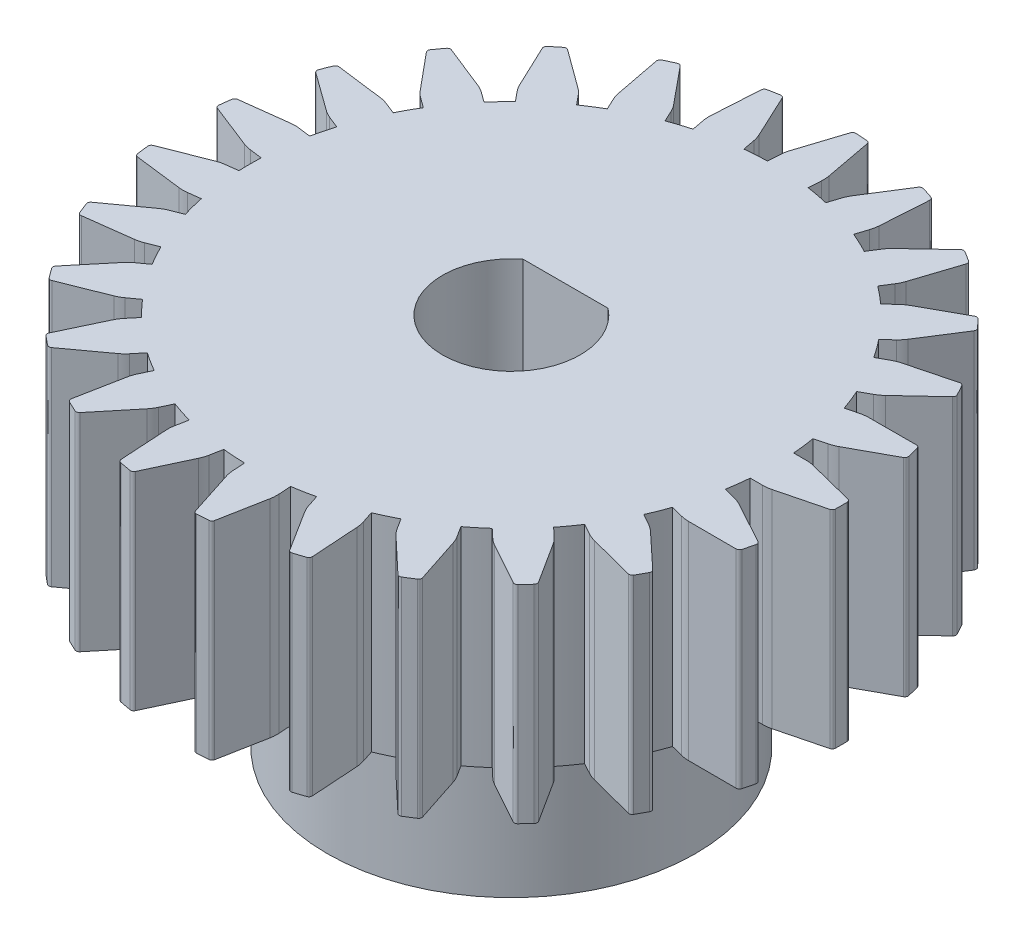
from build123d import *

# Parameters (mm, degrees)
BOSS_EXTRUDE1_DEPTH = 12.4
BOSS_EXTRUDE2_DEPTH = 10
SKETCH3_R           = 1
CUT_EXTRUDE1_DEPTH  = 10
CUT_EXTRUDE2_DEPTH  = 10


with BuildPart() as part:
    # Sketch1 → Boss-Extrude1 (new body)
    with BuildSketch(Plane(origin=(0, 0, 0), x_dir=(1, 0, 0), z_dir=(0, 1, 0))):
        with BuildLine():
            Line((-19.960600311, 2.711777504), (-17.312328167, 1.670742606))
            ThreePointArc((-17.312328167, 1.670742606), (-17.075641243, 1.594318398), (-16.831298839, 1.547862515))
            Line((-16.831298839, 1.547862515), (-16.087384111, 1.45388423))
            ThreePointArc((-16.087384111, 1.45388423), (-16.101516413, 0.788947145), (-16.087384111, 0.124010059))
            Line((-16.087384111, 0.124010059), (-16.831298839, 0.030031774))
            ThreePointArc((-16.831298839, 0.030031774), (-17.075641243, -0.016424108), (-17.312328167, -0.092848316))
            Line((-17.312328167, -0.092848316), (-19.960600311, -1.133883215))
            ThreePointArc((-19.960600311, -1.133883215), (-20.058551152, -1.21649133), (-20.086263615, -1.341593239))
            ThreePointArc((-20.086263615, -1.341593239), (-20.045781764, -1.686384218), (-19.999245773, -2.030410382))
            ThreePointArc((-19.999245773, -2.030410382), (-19.941292369, -2.144690175), (-19.825875031, -2.200343621))
            Line((-19.825875031, -2.200343621), (-17.001908374, -2.550073993))
            ThreePointArc((-17.001908374, -2.550073993), (-16.753651478, -2.56523555), (-16.505432431, -2.54946645))
            Line((-16.505432431, -2.54946645), (-15.761517704, -2.455488164))
            ThreePointArc((-15.761517704, -2.455488164), (-15.609842885, -3.103049589), (-15.430791446, -3.743581893))
            Line((-15.430791446, -3.743581893), (-16.127963275, -4.019611747))
            ThreePointArc((-16.127963275, -4.019611747), (-16.353076106, -4.125373617), (-16.563321147, -4.258258463))
            Line((-16.563321147, -4.258258463), (-18.869498101, -5.925185837))
            ThreePointArc((-18.869498101, -5.925185837), (-18.943827833, -6.02955805), (-18.939558078, -6.157621461))
            ThreePointArc((-18.939558078, -6.157621461), (-18.814602009, -6.481512771), (-18.683972204, -6.80315769))
            ThreePointArc((-18.683972204, -6.80315769), (-18.599419285, -6.899434747), (-18.473787545, -6.924636613))
            Line((-18.473787545, -6.924636613), (-15.651566587, -6.561087613))
            ThreePointArc((-15.651566587, -6.561087613), (-15.407338611, -6.514033862), (-15.170839438, -6.437030611))
            Line((-15.170839438, -6.437030611), (-14.473667609, -6.161000757))
            ThreePointArc((-14.473667609, -6.161000757), (-14.165715956, -6.750497855), (-13.832995841, -7.326378377))
            Line((-13.832995841, -7.326378377), (-14.439618902, -7.767115829))
            ThreePointArc((-14.439618902, -7.767115829), (-14.631357491, -7.92553828), (-14.801950181, -8.106534119))
            Line((-14.801950181, -8.106534119), (-16.621126364, -10.29461479))
            ThreePointArc((-16.621126364, -10.29461479), (-16.667164578, -10.414193011), (-16.631180889, -10.53717123))
            ThreePointArc((-16.631180889, -10.53717123), (-16.429602052, -10.819811588), (-16.223086384, -11.098865129))
            ThreePointArc((-16.223086384, -11.098865129), (-16.117246719, -11.171090009), (-15.989294482, -11.164256769))
            Line((-15.989294482, -11.164256769), (-13.346149745, -10.110271518))
            ThreePointArc((-13.346149745, -10.110271518), (-13.121296433, -10.003959019), (-12.911377246, -9.870560014))
            Line((-12.911377246, -9.870560014), (-12.304754185, -9.429822562))
            ThreePointArc((-12.304754185, -9.429822562), (-11.859875432, -9.924215063), (-11.39439267, -10.399259111))
            Line((-11.39439267, -10.399259111), (-11.872350605, -10.977011007))
            ThreePointArc((-11.872350605, -10.977011007), (-12.018667312, -11.178139773), (-12.138888684, -11.395873972))
            Line((-12.138888684, -11.395873972), (-13.356758567, -13.967622785))
            ThreePointArc((-13.356758567, -13.967622785), (-13.371612511, -14.094893475), (-13.306175877, -14.205059327))
            ThreePointArc((-13.306175877, -14.205059327), (-13.040640211, -14.4286894), (-12.771214818, -14.647617603))
            ThreePointArc((-12.771214818, -14.647617603), (-12.650738704, -14.691252152), (-12.52850568, -14.652813163))
            Line((-12.52850568, -14.652813163), (-10.230515668, -12.97461743))
            ThreePointArc((-10.230515668, -12.97461743), (-10.039165379, -12.815726189), (-9.869016173, -12.63431338))
            Line((-9.869016173, -12.63431338), (-9.391058239, -12.056561485))
            ThreePointArc((-9.391058239, -12.056561485), (-8.837205754, -12.424784889), (-8.268208338, -12.7691437))
            Line((-8.268208338, -12.7691437), (-8.587469292, -13.447607762))
            ThreePointArc((-8.587469292, -13.447607762), (-8.679170501, -13.678805183), (-8.741466603, -13.919596701))
            Line((-8.741466603, -13.919596701), (-9.281506943, -16.71342122))
            ThreePointArc((-9.281506943, -16.71342122), (-9.264243289, -16.840387493), (-9.173465334, -16.930818853))
            ThreePointArc((-9.173465334, -16.930818853), (-8.860657421, -17.081387142), (-8.545251293, -17.226433942))
            ThreePointArc((-8.545251293, -17.226433942), (-8.417708687, -17.23873644), (-8.308875225, -17.171106965))
            Line((-8.308875225, -17.171106965), (-6.500431103, -14.974147961))
            ThreePointArc((-6.500431103, -14.974147961), (-6.35460708, -14.772661699), (-6.234918955, -14.55463392))
            Line((-6.234918955, -14.55463392), (-5.915658002, -13.876169858))
            ThreePointArc((-5.915658002, -13.876169858), (-5.287632375, -14.095087335), (-4.650872505, -14.287123577))
            Line((-4.650872505, -14.287123577), (-4.791376138, -15.023669413))
            ThreePointArc((-4.791376138, -15.023669413), (-4.822699924, -15.270408506), (-4.823156465, -15.519127527))
            Line((-4.823156465, -15.519127527), (-4.651434539, -18.359481482))
            ThreePointArc((-4.651434539, -18.359481482), (-4.603138027, -18.478165579), (-4.492722664, -18.543180313))
            ThreePointArc((-4.492722664, -18.543180313), (-4.152297376, -18.611226057), (-3.810728639, -18.673277631))
            ThreePointArc((-3.810728639, -18.673277631), (-3.684133511, -18.653475067), (-3.59553802, -18.560904516))
            Line((-3.59553802, -18.560904516), (-2.390270982, -15.983225253))
            ThreePointArc((-2.390270982, -15.983225253), (-2.299135884, -15.751804093), (-2.237429286, -15.510860831))
            Line((-2.237429286, -15.510860831), (-2.096925653, -14.774314995))
            ThreePointArc((-2.096925653, -14.774314995), (-1.434188044, -14.830171155), (-0.769675685, -14.857818485))
            Line((-0.769675685, -14.857818485), (-0.722593637, -15.606166212))
            ThreePointArc((-0.722593637, -15.606166212), (-0.691571811, -15.852943452), (-0.630160104, -16.093962044))
            Line((-0.630160104, -16.093962044), (0.242534167, -18.80237555))
            ThreePointArc((0.242534167, -18.80237555), (0.31882889, -18.905320114), (0.441943858, -18.940833106))
            ThreePointArc((0.441943858, -18.940833106), (0.788596348, -18.922080742), (1.134865674, -18.897238161))
            ThreePointArc((1.134865674, -18.897238161), (1.252558885, -18.846574802), (1.315349627, -18.734879722))
            Line((1.315349627, -18.734879722), (1.841708219, -15.938445271))
            ThreePointArc((1.841708219, -15.938445271), (1.872428038, -15.691630254), (1.872275857, -15.442910861))
            Line((1.872275857, -15.442910861), (1.825193809, -14.694563134))
            ThreePointArc((1.825193809, -14.694563134), (2.48100116, -14.583848329), (3.131512253, -14.445369564))
            Line((3.131512253, -14.445369564), (3.363221644, -15.158497742))
            ThreePointArc((3.363221644, -15.158497742), (3.454639865, -15.389807206), (3.574061098, -15.607981285))
            Line((3.574061098, -15.607981285), (5.092893122, -18.014274761))
            ThreePointArc((5.092893122, -18.014274761), (5.192392178, -18.095011407), (5.320470985, -18.098791245))
            ThreePointArc((5.320470985, -18.098791245), (5.651569226, -17.994419052), (5.980781765, -17.884243267))
            ThreePointArc((5.980781765, -17.884243267), (6.082177964, -17.805902479), (6.115218582, -17.682101083))
            Line((6.115218582, -17.682101083), (5.929595683, -14.842621703))
            ThreePointArc((5.929595683, -14.842621703), (5.897969983, -14.595921126), (5.835968586, -14.355053556))
            Line((5.835968586, -14.355053556), (5.604259195, -13.641925379))
            ThreePointArc((5.604259195, -13.641925379), (6.2119295, -13.371596226), (6.807565322, -13.075692496))
            Line((6.807565322, -13.075692496), (7.209342902, -13.708792658))
            ThreePointArc((7.209342902, -13.708792658), (7.355413377, -13.910100323), (7.525340459, -14.09172121))
            Line((7.525340459, -14.09172121), (9.594876435, -16.044698387))
            ThreePointArc((9.594876435, -16.044698387), (9.711327932, -16.098154133), (9.836322916, -16.069963317))
            ThreePointArc((9.836322916, -16.069963317), (10.131062788, -15.886529384), (10.422532906, -15.697943144))
            ThreePointArc((10.422532906, -15.697943144), (10.501260995, -15.596847367), (10.502475426, -15.468718553))
            Line((10.502475426, -15.468718553), (9.616534405, -12.764609176))
            ThreePointArc((9.616534405, -12.764609176), (9.524550347, -12.533524143), (9.404595509, -12.315642991))
            Line((9.404595509, -12.315642991), (9.002817928, -11.682542829))
            ThreePointArc((9.002817928, -11.682542829), (9.524169027, -11.269585105), (10.027503589, -10.834849129))
            Line((10.027503589, -10.834849129), (10.574104195, -11.348141264))
            ThreePointArc((10.574104195, -11.348141264), (10.765648778, -11.506798229), (10.975404566, -11.640454014))
            Line((10.975404566, -11.640454014), (13.465607937, -13.017402154))
            ThreePointArc((13.465607937, -13.017402154), (13.5916948, -13.040218179), (13.705752066, -12.981828041))
            ThreePointArc((13.705752066, -12.981828041), (13.945613979, -12.730858197), (14.181027537, -12.47571107))
            ThreePointArc((14.181027537, -12.47571107), (14.232140741, -12.358212524), (14.201452677, -12.233807094))
            Line((14.201452677, -12.233807094), (12.670860467, -9.834976859))
            ThreePointArc((12.670860467, -9.834976859), (12.524297746, -9.634027293), (12.353926671, -9.452822833))
            Line((12.353926671, -9.452822833), (11.807326064, -8.939530697))
            ThreePointArc((11.807326064, -8.939530697), (12.209599549, -8.409892054), (12.589006489, -7.863639892))
            Line((12.589006489, -7.863639892), (13.246085196, -8.224871968))
            ThreePointArc((13.246085196, -8.224871968), (13.471068436, -8.330909232), (13.707473202, -8.408201832))
            Line((13.707473202, -8.408201832), (16.461875333, -9.122602218))
            ThreePointArc((16.461875333, -9.122602218), (16.589675061, -9.113344909), (16.68562797, -9.028424315))
            ThreePointArc((16.68562797, -9.028424315), (16.855540518, -8.725687919), (17.020105616, -8.420011737))
            ThreePointArc((17.020105616, -8.420011737), (17.040392304, -8.293493286), (16.979729991, -8.180628093))
            Line((16.979729991, -8.180628093), (14.900659329, -6.237804325))
            ThreePointArc((14.900659329, -6.237804325), (14.70872702, -6.079616625), (14.498644749, -5.9464746))
            Line((14.498644749, -5.9464746), (13.841566042, -5.585242524))
            ThreePointArc((13.841566042, -5.585242524), (14.099485591, -4.972202105), (14.331125376, -4.34875679))
            Line((14.331125376, -4.34875679), (15.057395512, -4.535231267))
            ThreePointArc((15.057395512, -4.535231267), (15.301680885, -4.581986119), (15.549880448, -4.598058955))
            Line((15.549880448, -4.598058955), (18.395412123, -4.605023184))
            ThreePointArc((18.395412123, -4.605023184), (18.516894587, -4.56427421), (18.588714067, -4.458159035))
            ThreePointArc((18.588714067, -4.458159035), (18.678001019, -4.122678127), (18.761377427, -3.785679648))
            ThreePointArc((18.761377427, -3.785679648), (18.749562912, -3.658090913), (18.662737985, -3.563857692))
            Line((18.662737985, -3.563857692), (16.165824528, -2.199115153))
            ThreePointArc((16.165824528, -2.199115153), (15.940582444, -2.093628835), (15.703989218, -2.016915048))
            Line((15.703989218, -2.016915048), (14.977719083, -1.830440572))
            ThreePointArc((14.977719083, -1.830440572), (15.075078663, -1.17251796), (15.144396513, -0.511052855))
            Line((15.144396513, -0.511052855), (15.894223853, -0.511052855))
            ThreePointArc((15.894223853, -0.511052855), (16.142462011, -0.495587515), (16.386861081, -0.449430672))
            Line((16.386861081, -0.449430672), (19.144727078, 0.251478844))
            ThreePointArc((19.144727078, 0.251478844), (19.25225909, 0.321159074), (19.295432458, 0.441801224))
            ThreePointArc((19.295432458, 0.441801224), (19.298483587, 0.788947145), (19.295432458, 1.136093066))
            ThreePointArc((19.295432458, 1.136093066), (19.25225909, 1.256735215), (19.144727078, 1.326415445))
            Line((19.144727078, 1.326415445), (16.386861081, 2.027324962))
            ThreePointArc((16.386861081, 2.027324962), (16.142462011, 2.073481805), (15.894223853, 2.088947144))
            Line((15.894223853, 2.088947144), (15.144396513, 2.088947144))
            ThreePointArc((15.144396513, 2.088947144), (15.075078663, 2.75041225), (14.977719083, 3.408334861))
            Line((14.977719083, 3.408334861), (15.703989218, 3.594809337))
            ThreePointArc((15.703989218, 3.594809337), (15.940582444, 3.671523125), (16.165824528, 3.777009442))
            Line((16.165824528, 3.777009442), (18.662737985, 5.141751981))
            ThreePointArc((18.662737985, 5.141751981), (18.749562912, 5.235985203), (18.761377427, 5.363573938))
            ThreePointArc((18.761377427, 5.363573938), (18.678001019, 5.700572416), (18.588714067, 6.036053324))
            ThreePointArc((18.588714067, 6.036053324), (18.516894587, 6.142168499), (18.395412123, 6.182917473))
            Line((18.395412123, 6.182917473), (15.549880448, 6.175953244))
            ThreePointArc((15.549880448, 6.175953244), (15.301680885, 6.159880408), (15.057395512, 6.113125556))
            Line((15.057395512, 6.113125556), (14.331125376, 5.92665108))
            ThreePointArc((14.331125376, 5.92665108), (14.099485591, 6.550096394), (13.841566042, 7.163136814))
            Line((13.841566042, 7.163136814), (14.498644749, 7.52436889))
            ThreePointArc((14.498644749, 7.52436889), (14.70872702, 7.657510915), (14.900659329, 7.815698614))
            Line((14.900659329, 7.815698614), (16.979729991, 9.758522383))
            ThreePointArc((16.979729991, 9.758522383), (17.040392304, 9.871387575), (17.020105616, 9.997906026))
            ThreePointArc((17.020105616, 9.997906026), (16.855540518, 10.303582208), (16.68562797, 10.606318605))
            ThreePointArc((16.68562797, 10.606318605), (16.589675061, 10.691239198), (16.461875333, 10.700496507))
            Line((16.461875333, 10.700496507), (13.707473202, 9.986096121))
            ThreePointArc((13.707473202, 9.986096121), (13.471068436, 9.908803521), (13.246085196, 9.802766258))
            Line((13.246085196, 9.802766258), (12.589006489, 9.441534182))
            ThreePointArc((12.589006489, 9.441534182), (12.209599549, 9.987786343), (11.807326064, 10.517424987))
            Line((11.807326064, 10.517424987), (12.353926671, 11.030717122))
            ThreePointArc((12.353926671, 11.030717122), (12.524297746, 11.211921582), (12.670860467, 11.412871148))
            Line((12.670860467, 11.412871148), (14.201452677, 13.811701384))
            ThreePointArc((14.201452677, 13.811701384), (14.232140741, 13.936106813), (14.181027537, 14.053605359))
            ThreePointArc((14.181027537, 14.053605359), (13.945613979, 14.308752487), (13.705752066, 14.55972233))
            ThreePointArc((13.705752066, 14.55972233), (13.5916948, 14.618112469), (13.465607937, 14.595296443))
            Line((13.465607937, 14.595296443), (10.975404566, 13.218348304))
            ThreePointArc((10.975404566, 13.218348304), (10.765648778, 13.084692518), (10.574104195, 12.926035554))
            Line((10.574104195, 12.926035554), (10.027503589, 12.412743418))
            ThreePointArc((10.027503589, 12.412743418), (9.524169027, 12.847479394), (9.002817928, 13.260437118))
            Line((9.002817928, 13.260437118), (9.404595509, 13.893537281))
            ThreePointArc((9.404595509, 13.893537281), (9.524550347, 14.111418433), (9.616534405, 14.342503466))
            Line((9.616534405, 14.342503466), (10.502475426, 17.046612842))
            ThreePointArc((10.502475426, 17.046612842), (10.501260995, 17.174741657), (10.422532906, 17.275837433))
            ThreePointArc((10.422532906, 17.275837433), (10.131062788, 17.464423673), (9.836322916, 17.647857606))
            ThreePointArc((9.836322916, 17.647857606), (9.711327932, 17.676048422), (9.594876435, 17.622592676))
            Line((9.594876435, 17.622592676), (7.525340459, 15.669615499))
            ThreePointArc((7.525340459, 15.669615499), (7.355413377, 15.487994613), (7.209342902, 15.286686948))
            Line((7.209342902, 15.286686948), (6.807565322, 14.653586785))
            ThreePointArc((6.807565322, 14.653586785), (6.2119295, 14.949490516), (5.604259195, 15.219819668))
            Line((5.604259195, 15.219819668), (5.835968586, 15.932947846))
            ThreePointArc((5.835968586, 15.932947846), (5.897969983, 16.173815416), (5.929595683, 16.420515992))
            Line((5.929595683, 16.420515992), (6.115218582, 19.259995373))
            ThreePointArc((6.115218582, 19.259995373), (6.082177964, 19.383796769), (5.980781765, 19.462137556))
            ThreePointArc((5.980781765, 19.462137556), (5.651569226, 19.572313341), (5.320470985, 19.676685534))
            ThreePointArc((5.320470985, 19.676685534), (5.192392178, 19.672905696), (5.092893122, 19.592169051))
            Line((5.092893122, 19.592169051), (3.574061098, 17.185875574))
            ThreePointArc((3.574061098, 17.185875574), (3.454639865, 16.967701495), (3.363221644, 16.736392031))
            Line((3.363221644, 16.736392031), (3.131512253, 16.023263853))
            ThreePointArc((3.131512253, 16.023263853), (2.48100116, 16.161742618), (1.825193809, 16.272457424))
            Line((1.825193809, 16.272457424), (1.872275857, 17.020805151))
            ThreePointArc((1.872275857, 17.020805151), (1.872428038, 17.269524544), (1.841708219, 17.51633956))
            Line((1.841708219, 17.51633956), (1.315349627, 20.312774012))
            ThreePointArc((1.315349627, 20.312774012), (1.252558885, 20.424469091), (1.134865674, 20.47513245))
            ThreePointArc((1.134865674, 20.47513245), (0.788596348, 20.499975031), (0.441943858, 20.518727395))
            ThreePointArc((0.441943858, 20.518727395), (0.31882889, 20.483214403), (0.242534167, 20.380269839))
            Line((0.242534167, 20.380269839), (-0.630160104, 17.671856333))
            ThreePointArc((-0.630160104, 17.671856333), (-0.691571811, 17.430837741), (-0.722593637, 17.184060502))
            Line((-0.722593637, 17.184060502), (-0.769675685, 16.435712774))
            ThreePointArc((-0.769675685, 16.435712774), (-1.434188044, 16.408065444), (-2.096925653, 16.352209284))
            Line((-2.096925653, 16.352209284), (-2.237429286, 17.088755121))
            ThreePointArc((-2.237429286, 17.088755121), (-2.299135884, 17.329698382), (-2.390270982, 17.561119543))
            Line((-2.390270982, 17.561119543), (-3.59553802, 20.138798805))
            ThreePointArc((-3.59553802, 20.138798805), (-3.684133511, 20.231369356), (-3.810728639, 20.25117192))
            ThreePointArc((-3.810728639, 20.25117192), (-4.152297376, 20.189120346), (-4.492722664, 20.121074602))
            ThreePointArc((-4.492722664, 20.121074602), (-4.603138027, 20.056059869), (-4.651434539, 19.937375771))
            Line((-4.651434539, 19.937375771), (-4.823156465, 17.097021816))
            ThreePointArc((-4.823156465, 17.097021816), (-4.822699924, 16.848302796), (-4.791376138, 16.601563703))
            Line((-4.791376138, 16.601563703), (-4.650872505, 15.865017866))
            ThreePointArc((-4.650872505, 15.865017866), (-5.287632375, 15.672981625), (-5.915658002, 15.454064147))
            Line((-5.915658002, 15.454064147), (-6.234918955, 16.132528209))
            ThreePointArc((-6.234918955, 16.132528209), (-6.35460708, 16.350555988), (-6.500431103, 16.55204225))
            Line((-6.500431103, 16.55204225), (-8.308875225, 18.749001254))
            ThreePointArc((-8.308875225, 18.749001254), (-8.417708687, 18.816630729), (-8.545251293, 18.804328231))
            ThreePointArc((-8.545251293, 18.804328231), (-8.860657421, 18.659281431), (-9.173465334, 18.508713142))
            ThreePointArc((-9.173465334, 18.508713142), (-9.264243289, 18.418281782), (-9.281506943, 18.29131551))
            Line((-9.281506943, 18.29131551), (-8.741466603, 15.497490991))
            ThreePointArc((-8.741466603, 15.497490991), (-8.679170501, 15.256699473), (-8.587469292, 15.025502051))
            Line((-8.587469292, 15.025502051), (-8.268208338, 14.347037989))
            ThreePointArc((-8.268208338, 14.347037989), (-8.837205754, 14.002679179), (-9.391058239, 13.634455774))
            Line((-9.391058239, 13.634455774), (-9.869016173, 14.212207669))
            ThreePointArc((-9.869016173, 14.212207669), (-10.039165379, 14.393620478), (-10.230515668, 14.552511719))
            Line((-10.230515668, 14.552511719), (-12.52850568, 16.230707452))
            ThreePointArc((-12.52850568, 16.230707452), (-12.650738704, 16.269146441), (-12.771214818, 16.225511892))
            ThreePointArc((-12.771214818, 16.225511892), (-13.040640211, 16.006583689), (-13.306175877, 15.782953616))
            ThreePointArc((-13.306175877, 15.782953616), (-13.371612511, 15.672787764), (-13.356758567, 15.545517074))
            Line((-13.356758567, 15.545517074), (-12.138888684, 12.973768261))
            ThreePointArc((-12.138888684, 12.973768261), (-12.018667312, 12.756034062), (-11.872350605, 12.554905296))
            Line((-11.872350605, 12.554905296), (-11.39439267, 11.977153401))
            ThreePointArc((-11.39439267, 11.977153401), (-11.859875432, 11.502109352), (-12.304754185, 11.007716851))
            Line((-12.304754185, 11.007716851), (-12.911377246, 11.448454304))
            ThreePointArc((-12.911377246, 11.448454304), (-13.121296433, 11.581853309), (-13.346149745, 11.688165807))
            Line((-13.346149745, 11.688165807), (-15.989294482, 12.742151058))
            ThreePointArc((-15.989294482, 12.742151058), (-16.117246719, 12.748984299), (-16.223086384, 12.676759418))
            ThreePointArc((-16.223086384, 12.676759418), (-16.429602052, 12.397705877), (-16.631180889, 12.115065519))
            ThreePointArc((-16.631180889, 12.115065519), (-16.667164578, 11.992087301), (-16.621126364, 11.87250908))
            Line((-16.621126364, 11.87250908), (-14.801950181, 9.684428408))
            ThreePointArc((-14.801950181, 9.684428408), (-14.631357491, 9.503432569), (-14.439618902, 9.345010118))
            Line((-14.439618902, 9.345010118), (-13.832995841, 8.904272666))
            ThreePointArc((-13.832995841, 8.904272666), (-14.165715956, 8.328392144), (-14.473667609, 7.738895046))
            Line((-14.473667609, 7.738895046), (-15.170839438, 8.0149249))
            ThreePointArc((-15.170839438, 8.0149249), (-15.407338611, 8.091928151), (-15.651566587, 8.138981902))
            Line((-15.651566587, 8.138981902), (-18.473787545, 8.502530902))
            ThreePointArc((-18.473787545, 8.502530902), (-18.599419285, 8.477329036), (-18.683972204, 8.381051979))
            ThreePointArc((-18.683972204, 8.381051979), (-18.814602009, 8.05940706), (-18.939558078, 7.73551575))
            ThreePointArc((-18.939558078, 7.73551575), (-18.943827833, 7.607452339), (-18.869498101, 7.503080126))
            Line((-18.869498101, 7.503080126), (-16.563321147, 5.836152752))
            ThreePointArc((-16.563321147, 5.836152752), (-16.353076106, 5.703267907), (-16.127963275, 5.597506037))
            Line((-16.127963275, 5.597506037), (-15.430791446, 5.321476183))
            ThreePointArc((-15.430791446, 5.321476183), (-15.609842885, 4.680943879), (-15.761517704, 4.033382454))
            Line((-15.761517704, 4.033382454), (-16.505432431, 4.127360739))
            ThreePointArc((-16.505432431, 4.127360739), (-16.753651478, 4.143129839), (-17.001908374, 4.127968282))
            Line((-17.001908374, 4.127968282), (-19.825875031, 3.77823791))
            ThreePointArc((-19.825875031, 3.77823791), (-19.941292369, 3.722584464), (-19.999245773, 3.608304671))
            ThreePointArc((-19.999245773, 3.608304671), (-20.045781764, 3.264278508), (-20.086263615, 2.919487528))
            ThreePointArc((-20.086263615, 2.919487528), (-20.058551152, 2.79438562), (-19.960600311, 2.711777504))
        make_face()
        with BuildLine():
            Line((2.088783766, 4.038947145), (-2.991816592, 4.038947145))
            ThreePointArc((-2.991816592, 4.038947145), (-4.159235607, 2.596830819), (-4.576516413, 0.788947145))
            ThreePointArc((-4.576516413, 0.788947145), (-0.451516413, -3.336052855), (3.673483587, 0.788947145))
            ThreePointArc((3.673483587, 0.788947145), (3.256202781, 2.596830819), (2.088783766, 4.038947145))
        make_face(mode=Mode.SUBTRACT)
    extrude(amount=BOSS_EXTRUDE1_DEPTH)

    # Sketch2 → Boss-Extrude2 (add)
    with BuildSketch(Plane.XZ):
        with BuildLine():
            Line((4.070996716, -12.038947145), (-4.974029542, -12.038947145))
            ThreePointArc((-4.974029542, -12.038947145), (-0.451516413, 11.336052855), (4.070996716, -12.038947145))
        make_face()
        with BuildLine():
            Line((2.088783766, -4.038947145), (-2.991816592, -4.038947145))
            ThreePointArc((-2.991816592, -4.038947145), (-0.451516413, 3.336052855), (2.088783766, -4.038947145))
        make_face(mode=Mode.SUBTRACT)
    extrude(amount=BOSS_EXTRUDE2_DEPTH)

    # Sketch3 → Cut-Extrude1 (cut)
    with BuildSketch(Plane(origin=(0, 0, -12.038947145), x_dir=(-1, 0, 0), z_dir=(0, 0, -1))):
        with Locations((0.451516413, -5)):
            Circle(SKETCH3_R)
    extrude(amount=-CUT_EXTRUDE1_DEPTH, mode=Mode.SUBTRACT)

    # Sketch6 → Cut-Extrude2 (cut)
    with BuildSketch(Plane.XZ.offset(10)):
        with BuildLine():
            Line((-4.974029542, -12.038947145), (4.070996716, -12.038947145))
            ThreePointArc((4.070996716, -12.038947145), (-0.451516413, 11.336052855), (-4.974029542, -12.038947145))
        make_face()
        with BuildLine():
            Line((-4.563739691, -11.018328588), (3.660706865, -11.018328588))
            ThreePointArc((3.660706865, -11.018328588), (-0.451516413, 10.236052855), (-4.563739691, -11.018328588))
        make_face(mode=Mode.SUBTRACT)
    extrude(amount=-CUT_EXTRUDE2_DEPTH, mode=Mode.SUBTRACT)


solid = part.part
